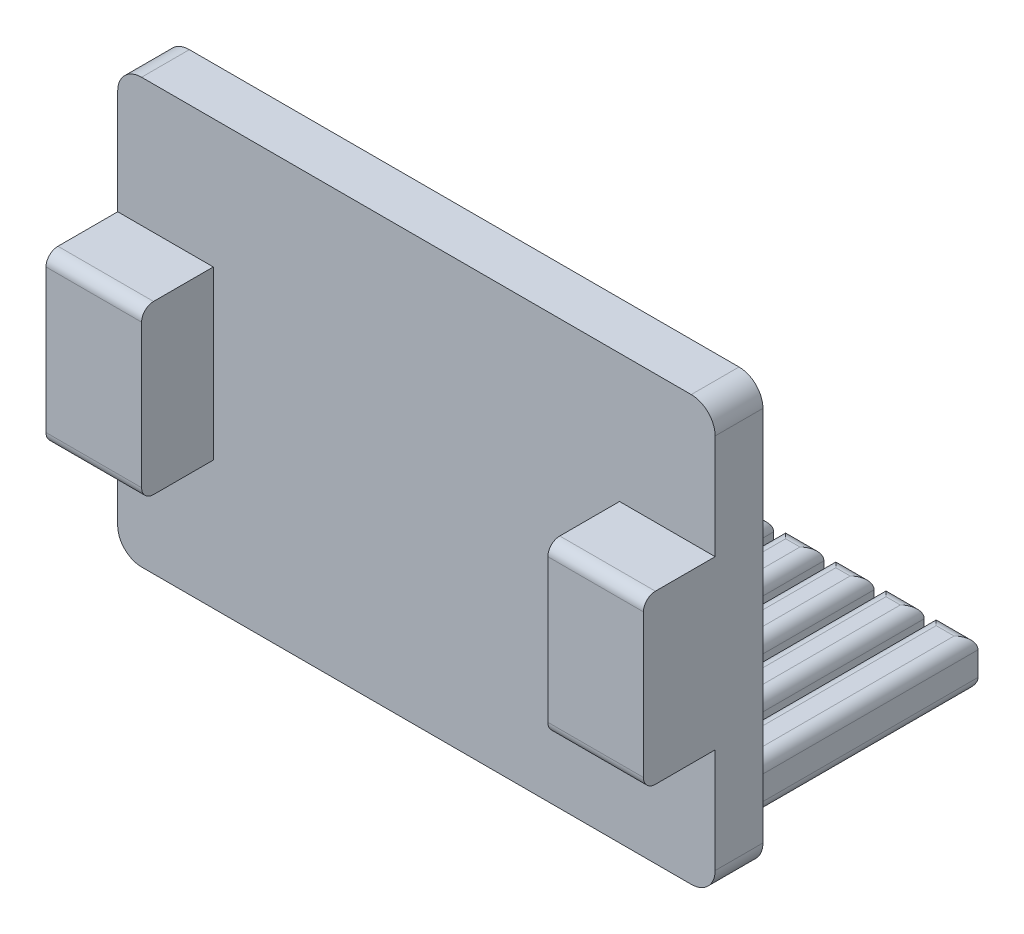
from build123d import *

# Parameters (mm, degrees)
SKETCH1_W           = 25
SKETCH1_H           = 17.75
BOSS_EXTRUDE1_DEPTH = 2
BOSS_EXTRUDE2_DEPTH = 3
SKETCH3_W           = 23
SKETCH3_H           = 2
BOSS_EXTRUDE3_DEPTH = 10
CUT_EXTRUDE1_DEPTH  = 8
FILLET1_R           = 1
FILLET2_R           = 0.5
FILLET3_R           = 0.5


with BuildPart() as part:
    # Sketch1 → Boss-Extrude1 (new body)
    with BuildSketch(Plane.XY):
        with Locations((12.5, 8.875)):
            Rectangle(SKETCH1_W, SKETCH1_H)
    extrude(amount=BOSS_EXTRUDE1_DEPTH)

    # Sketch2 → Boss-Extrude2 (add)
    with BuildSketch(Plane.XY.offset(2)):
        Polygon((0, 8.875), (0, 12.375), (4, 12.375), (4, 5.375), (0, 5.375), align=None)
        Polygon((21, 8.875), (21, 12.375), (25, 12.375), (25, 5.375), (21, 5.375), align=None)
    extrude(amount=BOSS_EXTRUDE2_DEPTH)

    # Sketch3 → Boss-Extrude3 (add)
    with BuildSketch(Plane(origin=(0, 0, 0), x_dir=(-1, 0, 0), z_dir=(0, 0, -1))):
        with Locations((-12.5, 2)):
            Rectangle(SKETCH3_W, SKETCH3_H)
    extrude(amount=BOSS_EXTRUDE3_DEPTH)

    # Sketch4 → Cut-Extrude1 (cut)
    with BuildSketch(Plane(origin=(0, 0, -10), x_dir=(-1, 0, 0), z_dir=(0, 0, -1))):
        Polygon((-19.9, 3), (-20.15, 3), (-20.15, 1), (-19.65, 1), (-19.65, 3), align=None)
        Polygon((-22, 3), (-22.25, 3), (-22.25, 1), (-21.75, 1), (-21.75, 3), align=None)
        Polygon((-17.8, 3), (-18.05, 3), (-18.05, 1), (-17.55, 1), (-17.55, 3), align=None)
        Polygon((-15.7, 3), (-15.95, 3), (-15.95, 1), (-15.45, 1), (-15.45, 3), align=None)
        Polygon((-13.6, 3), (-13.85, 3), (-13.85, 1), (-13.35, 1), (-13.35, 3), align=None)
        Polygon((-11.5, 3), (-11.75, 3), (-11.75, 1), (-11.25, 1), (-11.25, 3), align=None)
        Polygon((-9.4, 3), (-9.65, 3), (-9.65, 1), (-9.15, 1), (-9.15, 3), align=None)
        Polygon((-7.3, 3), (-7.55, 3), (-7.55, 1), (-7.05, 1), (-7.05, 3), align=None)
        Polygon((-5.2, 3), (-5.45, 3), (-5.45, 1), (-4.95, 1), (-4.95, 3), align=None)
        Polygon((-3.1, 3), (-3.35, 3), (-3.35, 1), (-2.85, 1), (-2.85, 3), align=None)
    extrude(amount=-CUT_EXTRUDE1_DEPTH, mode=Mode.SUBTRACT)

    # Fillet1
    fillet1_edges = [part.edges().sort_by_distance(p)[0] for p in [
        (0, 0, 1),
        (0, 17.75, 1),
        (25, 17.75, 1),
        (25, 0, 1),
    ]]
    fillet(fillet1_edges, radius=FILLET1_R)

    # Fillet2
    fillet2_edges = [part.edges().sort_by_distance(p)[0] for p in [
        (21.75, 3, -6),
        (22, 1, -2),
        (21.75, 1, -6),
        (22.25, 1, -6),
        (22, 3, -2),
        (22.25, 3, -6),
        (19.65, 3, -6),
        (19.9, 1, -2),
        (19.65, 1, -6),
        (20.15, 1, -6),
        (19.9, 3, -2),
        (20.15, 3, -6),
        (17.55, 3, -6),
        (17.8, 1, -2),
        (17.55, 1, -6),
        (18.05, 1, -6),
        (17.8, 3, -2),
        (18.05, 3, -6),
        (15.45, 3, -6),
        (15.7, 1, -2),
        (15.45, 1, -6),
        (15.95, 1, -6),
        (15.7, 3, -2),
        (15.95, 3, -6),
        (13.35, 3, -6),
        (13.6, 1, -2),
        (13.35, 1, -6),
        (13.85, 1, -6),
        (13.6, 3, -2),
        (13.85, 3, -6),
        (11.25, 3, -6),
        (11.5, 1, -2),
        (11.25, 1, -6),
        (11.75, 1, -6),
        (11.5, 3, -2),
        (11.75, 3, -6),
        (9.15, 3, -6),
        (9.4, 1, -2),
        (9.15, 1, -6),
        (9.65, 1, -6),
        (9.4, 3, -2),
        (9.65, 3, -6),
        (7.05, 3, -6),
        (7.3, 1, -2),
        (7.05, 1, -6),
        (7.55, 1, -6),
        (7.3, 3, -2),
        (7.55, 3, -6),
        (4.95, 3, -6),
        (5.2, 1, -2),
        (4.95, 1, -6),
        (5.45, 1, -6),
        (5.2, 3, -2),
        (5.45, 3, -6),
        (2.85, 3, -6),
        (3.1, 1, -2),
        (2.85, 1, -6),
        (3.35, 1, -6),
        (3.1, 3, -2),
        (3.35, 3, -6),
        (12.5, 1, 0),
        (24, 1, -5),
        (1, 2, 0),
        (1, 1, -5),
        (12.5, 3, 0),
        (1, 3, -5),
        (24, 2, 0),
        (24, 3, -5),
        (23.125, 1, -10),
        (1.925, 3, -10),
        (20.95, 1, -10),
        (18.85, 1, -10),
        (16.75, 1, -10),
        (14.65, 1, -10),
        (12.55, 1, -10),
        (10.45, 1, -10),
        (8.35, 1, -10),
        (6.25, 1, -10),
        (4.15, 1, -10),
        (1.925, 1, -10),
        (4.15, 3, -10),
        (6.25, 3, -10),
        (8.35, 3, -10),
        (10.45, 3, -10),
        (12.55, 3, -10),
        (14.65, 3, -10),
        (16.75, 3, -10),
        (18.85, 3, -10),
        (20.95, 3, -10),
        (23.125, 3, -10),
    ]]
    fillet(fillet2_edges, radius=FILLET2_R)

    # Fillet3
    fillet3_edges = [part.edges().sort_by_distance(p)[0] for p in [
        (2, 5.375, 5),
        (2, 12.375, 5),
        (23, 5.375, 5),
        (23, 12.375, 5),
    ]]
    fillet(fillet3_edges, radius=FILLET3_R)


solid = part.part
